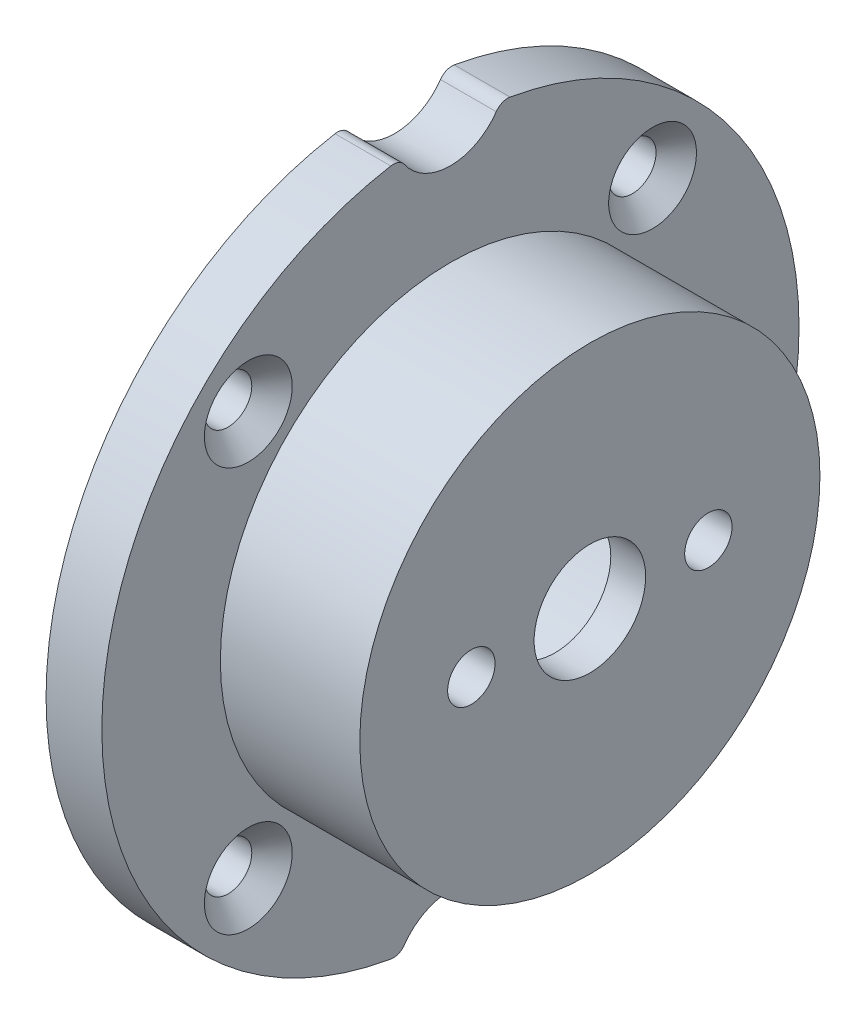
from build123d import *

# Parameters (mm, degrees)
SKETCH1_R                                       = 25
BOSS_EXTRUDE1_DEPTH                             = 4
SKETCH2_R                                       = 16.5
BOSS_EXTRUDE2_DEPTH                             = 10
SKETCH3_R                                       = 12.5
CUT_EXTRUDE1_DEPTH                              = 11.5
SKETCH4_R                                       = 4
CUT_EXTRUDE2_DEPTH                              = 4
M3_CLEARANCE_HOLE1_D                            = 3.4
M3_CLEARANCE_HOLE1_DEPTH                        = 10
CSK_FOR_M3_FLAT_HEAD_MACHINE_SCREW1_D           = 3.4
CSK_FOR_M3_FLAT_HEAD_MACHINE_SCREW1_CSINK_D     = 6.3
CSK_FOR_M3_FLAT_HEAD_MACHINE_SCREW1_CSINK_ANGLE = 90
CIRPATTERN1_COUNT                               = 4
SKETCH10_R                                      = 13.125
CUT_EXTRUDE3_DEPTH                              = 11.5
SKETCH12_R                                      = 4
CUT_EXTRUDE4_DEPTH                              = 10
FILLET1_R                                       = 1


with BuildPart() as part:
    # Sketch1 → Boss-Extrude1 (new body)
    with BuildSketch(Plane(origin=(0, 0, 0), x_dir=(0, 0, -1), z_dir=(1, 0, 0))):
        Circle(SKETCH1_R)
    extrude(amount=BOSS_EXTRUDE1_DEPTH)

    # Sketch2 → Boss-Extrude2 (add)
    with BuildSketch(Plane(origin=(4, 0, 0), x_dir=(0, 0, -1), z_dir=(1, 0, 0))):
        Circle(SKETCH2_R)
    extrude(amount=BOSS_EXTRUDE2_DEPTH)

    # Sketch3 → Cut-Extrude1 (cut)
    with BuildSketch(Plane.ZY):
        Circle(SKETCH3_R)
    extrude(amount=-CUT_EXTRUDE1_DEPTH, mode=Mode.SUBTRACT)

    # Sketch4 → Cut-Extrude2 (cut)
    with BuildSketch(Plane(origin=(14, 0, 0), x_dir=(0, 0, -1), z_dir=(1, 0, 0))):
        Circle(SKETCH4_R)
    extrude(amount=-CUT_EXTRUDE2_DEPTH, mode=Mode.SUBTRACT)

    # M3 Clearance Hole1
    with Locations(Plane(origin=(14, 0, 0), x_dir=(0, 0, -1), z_dir=(1, 0, 0))):
        with Locations((8.5, 0), (-8.5, 0)):
            Hole(M3_CLEARANCE_HOLE1_D / 2, depth=M3_CLEARANCE_HOLE1_DEPTH)

    # CSK for M3 Flat Head Machine Screw1 (through all)
    with Locations(Plane(origin=(4, 0, 0), x_dir=(0, 0, -1), z_dir=(1, 0, 0))):
        with Locations((-14.495689014, -14.495689014)):
            csk_for_m3_flat_head_machine_screw1 = CounterSinkHole(CSK_FOR_M3_FLAT_HEAD_MACHINE_SCREW1_D / 2, CSK_FOR_M3_FLAT_HEAD_MACHINE_SCREW1_CSINK_D / 2, counter_sink_angle=CSK_FOR_M3_FLAT_HEAD_MACHINE_SCREW1_CSINK_ANGLE)

    # CirPattern1: CSK for M3 Flat Head Machine Screw1 ×4 about axis
    cirpattern1_axis = Axis((0, 0, 0), (1, 0, 0))
    for i in range(1, CIRPATTERN1_COUNT):
        add(csk_for_m3_flat_head_machine_screw1.rotate(cirpattern1_axis, i * 360 / CIRPATTERN1_COUNT), mode=Mode.SUBTRACT)

    # Sketch10 → Cut-Extrude3 (cut)
    with BuildSketch(Plane.ZY):
        Circle(SKETCH10_R)
    extrude(amount=-CUT_EXTRUDE3_DEPTH, mode=Mode.SUBTRACT)

    # Sketch12 → Cut-Extrude4 (cut)
    with BuildSketch(Plane(origin=(4, 0, 0), x_dir=(0, 0, -1), z_dir=(1, 0, 0))):
        with Locations((0, 26.5)):
            Circle(SKETCH12_R)
        with Locations((0, -26.5)):
            Circle(SKETCH12_R)
    extrude(amount=-CUT_EXTRUDE4_DEPTH, mode=Mode.SUBTRACT)

    # Fillet1
    fillet1_edges = [part.edges().sort_by_distance(p)[0] for p in [
        (2, 24.740566038, -3.592268383),
        (2, 24.740566038, 3.592268383),
        (2, -24.740566038, 3.592268383),
        (2, -24.740566038, -3.592268383),
    ]]
    fillet(fillet1_edges, radius=FILLET1_R)


solid = part.part
